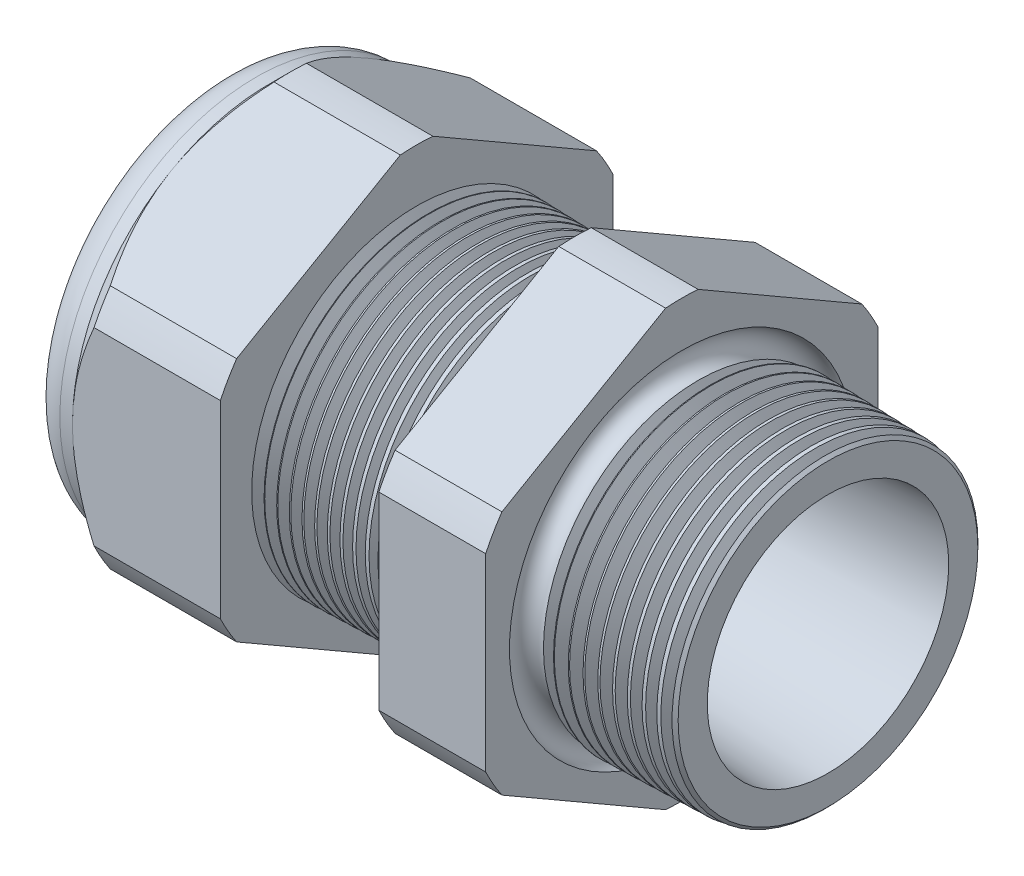
from build123d import *

# Parameters (mm, degrees)
SKETCH12_OUTSIDE_W = 65.136
SKETCH12_OUTSIDE_H = 65.136
CUT_EXTRUDE2_DEPTH = 35.03
FILLET4_R          = 2.032
SKETCH19_OUTSIDE_W = 40.13
SKETCH19_OUTSIDE_H = 42.756
SKETCH19_OUTSIDE_R = 11.938
CUT_EXTRUDE3_DEPTH = 1.999996
CUT_EXTRUDE3_DRAFT = -45
CHAMFER1_SIZE      = 0.260919487
CHAMFER1_SIZE2     = 0.254
SKETCH21_R         = 5.969
PLUG_DEPTH         = 6.35
SKETCH22_R         = 5.715
CUT_EXTRUDE4_DEPTH = 0.508
SKETCH27_R         = 2.032
PLUGHOLES_DEPTH    = 37.322
CIRPATTERN1_COUNT  = 4
LPATTERN1_COUNT    = 13
LPATTERN1_PITCH    = 0.762
LPATTERN2_COUNT    = 10
LPATTERN2_PITCH    = 0.889
SKETCH32_R         = 0.889


with BuildPart() as part:
    # Sketch10 → Revolve2 (revolve)
    with BuildSketch(Plane.XY, mode=Mode.PRIVATE) as revolve2_sk:
        Polygon((-35.814, 5.969), (-24.014, 5.969), (1.016, 7.345566383), (1.016, 9.377566383), (-7.874, 9.610359226), (-7.874, 23.876), (-14.374, 23.876), (-14.374, 9.780567716), (-24.014, 10.033), (-24.014, 23.876), (-33.014, 23.876), (-33.014, 11.938), (-35.814, 11.938), align=None)
    revolve(revolve2_sk.sketch.rotate(Axis((0, 0, 0), (-1, 0, 0)), 90), axis=Axis((0, 0, 0), (-1, 0, 0)))  # turned: the seam where the file's is

    # Sketch12 outside → Cut-Extrude2 (cut, through all)
    with BuildSketch(Plane.ZY.offset(33.014)):
        Rectangle(SKETCH12_OUTSIDE_W, SKETCH12_OUTSIDE_H)
        with BuildLine():
            Line((-0.98819228, 13.214281948), (-10.94980772, 7.462940592))
            ThreePointArc((-10.94980772, 7.462940592), (-11.47585851, 6.62559), (-11.938, 5.751341356))
            Line((-11.938, 5.751341356), (-11.938, -5.751341356))
            ThreePointArc((-11.938, -5.751341356), (-11.47585851, -6.62559), (-10.94980772, -7.462940592))
            Line((-10.94980772, -7.462940592), (-0.98819228, -13.214281948))
            ThreePointArc((-0.98819228, -13.214281948), (0, -13.25118), (0.98819228, -13.214281948))
            Line((0.98819228, -13.214281948), (10.94980772, -7.462940592))
            ThreePointArc((10.94980772, -7.462940592), (11.47585851, -6.62559), (11.938, -5.751341356))
            Line((11.938, -5.751341356), (11.938, 5.751341356))
            ThreePointArc((11.938, 5.751341356), (11.47585851, 6.62559), (10.94980772, 7.462940592))
            Line((10.94980772, 7.462940592), (0.98819228, 13.214281948))
            ThreePointArc((0.98819228, 13.214281948), (0, 13.25118), (-0.98819228, 13.214281948))
        make_face(mode=Mode.SUBTRACT)
    extrude(amount=-CUT_EXTRUDE2_DEPTH, mode=Mode.SUBTRACT)

    # Fillet4
    fillet4_edges = [part.edges().sort_by_distance(p)[0] for p in [
        (-35.814, 0, 11.938),
    ]]
    fillet(fillet4_edges, radius=FILLET4_R)


with BuildPart() as cut_extrude3_tool:
    # Sketch19 outside → Cut-Extrude3 (with draft: the straight prism first)
    with BuildSketch(Plane.ZY.offset(33.014)):
        Rectangle(SKETCH19_OUTSIDE_W, SKETCH19_OUTSIDE_H)
        Circle(SKETCH19_OUTSIDE_R, mode=Mode.SUBTRACT)
    extrude(amount=-CUT_EXTRUDE3_DEPTH)
    # Cut-Extrude3: the draft: its side faces are tilted about the plane it starts from
    cut_extrude3_sides = [cut_extrude3_tool.faces().sort_by_distance(p)[0] for p in [
        (-32.014002, -21.378, 0),
        (-32.014002, 0, 20.065),
        (-32.014002, 21.378, 0),
        (-32.014002, 0, -20.065),
        (-32.014002, 0, -11.938),
    ]]
    draft(cut_extrude3_sides, Plane.ZY.offset(33.014), CUT_EXTRUDE3_DRAFT)


with BuildPart() as part_1:
    add(part.part)

    # Cut-Extrude3: cut by cut_extrude3_tool
    add(cut_extrude3_tool.part, mode=Mode.SUBTRACT)

    # Chamfer1
    chamfer1_edges = [part_1.edges().sort_by_distance(p)[0] for p in [
        (1.016, 0, 9.377566383),
    ]]
    chamfer1_side = [part_1.faces().sort_by_distance(p)[0] for p in [
        (1.016, 0, 7.610804014),
    ]]
    chamfer(chamfer1_edges, length=CHAMFER1_SIZE, length2=CHAMFER1_SIZE2, reference=chamfer1_side[0])

    # Sketch29 → Cut-Revolve1 (revolve, cut)
    with BuildSketch(Plane.XY, mode=Mode.PRIVATE) as cut_revolve1_sk:
        Polygon((-24.014, 10.033), (-23.281016419, 10.013806149), (-23.664130572, 9.388620673), align=None)
    cut_revolve1 = revolve(cut_revolve1_sk.sketch.rotate(Axis((0, 0, 0), (-1, 0, 0)), 90), axis=Axis((0, 0, 0), (-1, 0, 0)), mode=Mode.SUBTRACT)  # turned: the seam where the file's is

    # LPattern1: Cut-Revolve1 ×13
    with Locations(*[(i * LPATTERN1_PITCH, 0, 0) for i in range(1, LPATTERN1_COUNT)]):
        add(cut_revolve1, mode=Mode.SUBTRACT)

    # Sketch30 → Cut-Revolve2 (revolve, cut)
    with BuildSketch(Plane.XY, mode=Mode.PRIVATE) as cut_revolve2_sk:
        Polygon((-7.874, 9.610359226), (-6.994419703, 9.587326605), (-7.454156686, 8.837104034), align=None)
    cut_revolve2 = revolve(cut_revolve2_sk.sketch.rotate(Axis((0, 0, 0), (-1, 0, 0)), 270), axis=Axis((0, 0, 0), (-1, 0, 0)), mode=Mode.SUBTRACT)  # turned: the seam where the file's is

    # LPattern2: Cut-Revolve2 ×10
    with Locations(*[(i * LPATTERN2_PITCH, 0, 0) for i in range(1, LPATTERN2_COUNT)]):
        add(cut_revolve2, mode=Mode.SUBTRACT)

    # Sketch32 → Cut-Revolve3 (revolve, cut)
    with BuildSketch(Plane.XY, mode=Mode.PRIVATE) as cut_revolve3_sk:
        with Locations((-7.747, 9.610359226)):
            Circle(SKETCH32_R)
    revolve(cut_revolve3_sk.sketch.rotate(Axis((0, 0, 0), (-1, 0, 0)), 270), axis=Axis((0, 0, 0), (-1, 0, 0)), mode=Mode.SUBTRACT)  # turned: the seam where the file's is


with BuildPart() as body_2:
    # Sketch21 → plug (new body)
    with BuildSketch(Plane.ZY.offset(35.814)):
        Circle(SKETCH21_R)
    extrude(amount=-PLUG_DEPTH)

    # Sketch22 → Cut-Extrude4 (cut)
    with BuildSketch(Plane.ZY.offset(35.814)):
        Circle(SKETCH22_R)
    extrude(amount=-CUT_EXTRUDE4_DEPTH, mode=Mode.SUBTRACT)

    # Sketch27 → plugholes (cut, through all)
    with BuildSketch(Plane.ZY.offset(35.306)):
        with Locations((-3.674872, 0)):
            Circle(SKETCH27_R)
    plugholes = extrude(amount=-PLUGHOLES_DEPTH, mode=Mode.SUBTRACT)

    # CirPattern1: plugholes ×4 about axis
    cirpattern1_axis = Axis((0, 0, 0), (1, 0, 0))
    for i in range(1, CIRPATTERN1_COUNT):
        add(plugholes.rotate(cirpattern1_axis, i * 360 / CIRPATTERN1_COUNT), mode=Mode.SUBTRACT)


solid = Compound([part_1.part, body_2.part])
